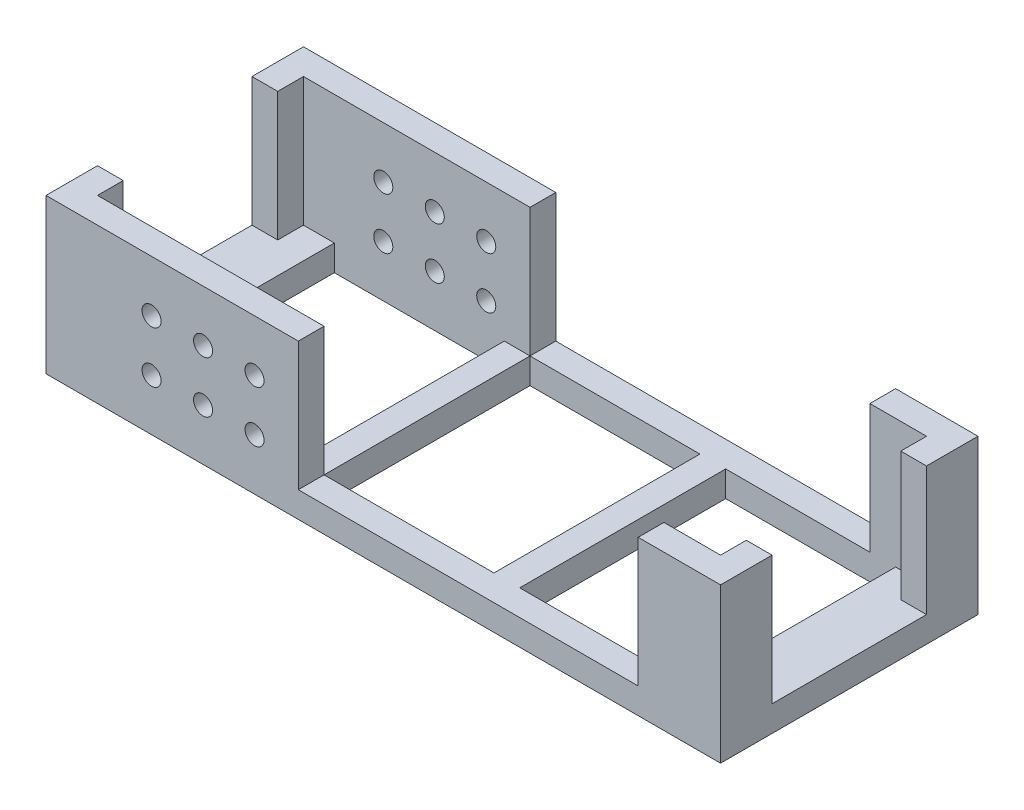
from build123d import *

# Parameters (mm, degrees)
SKETCH1_W                = 131
SKETCH1_H                = 50
BOSS_EXTRUDE6_DEPTH      = 5
SKETCH11_W               = 33
SKETCH11_H               = 40
CUT_EXTRUDE7_DEPTH       = 5
BOSS_EXTRUDE7_DEPTH      = 30
SKETCH13_W               = 30
SKETCH13_H               = 25
CUT_EXTRUDE8_DEPTH       = 66.5
CUT_EXTRUDE8_DEPTH_BACK  = 66.5
SKETCH15_R               = 1.85
CUT_EXTRUDE10_DEPTH      = 26
CUT_EXTRUDE10_DEPTH_BACK = 26


with BuildPart() as part:
    # Sketch1 → Boss-Extrude6 (new body)
    with BuildSketch(Plane(origin=(0, 0, 0), x_dir=(1, 0, 0), z_dir=(0, 1, 0))):
        Rectangle(SKETCH1_W, SKETCH1_H)
    extrude(amount=BOSS_EXTRUDE6_DEPTH)

    # Sketch11 → Cut-Extrude7 (cut)
    with BuildSketch(Plane(origin=(0, 0, 0), x_dir=(1, 0, 0), z_dir=(0, 1, 0))):
        with Locations((38, 0)):
            Rectangle(SKETCH11_W, SKETCH11_H)
        Rectangle(SKETCH11_W, SKETCH11_H)
        with Locations((-38, 0)):
            Rectangle(SKETCH11_W, SKETCH11_H)
    extrude(amount=CUT_EXTRUDE7_DEPTH, mode=Mode.SUBTRACT)

    # Sketch12 → Boss-Extrude7 (add)
    with BuildSketch(Plane(origin=(0, 0, 0), x_dir=(1, 0, 0), z_dir=(0, 1, 0))):
        Polygon((-65.5, -20), (-65.5, -25), (-59, -25), (-16.5, -25), (-16.5, -20), (-60.5, -20), (-60.5, 20), (-16.5, 20), (-16.5, 25), (-59, 25), (-65.5, 25), (-65.5, 20), align=None)
        Polygon((49.5, 25), (49.5, 20), (60.5, 20), (60.5, -20), (49.5, -20), (49.5, -25), (65.5, -25), (65.5, 25), align=None)
    extrude(amount=BOSS_EXTRUDE7_DEPTH)

    # Sketch13 → Cut-Extrude8 (cut, two sides)
    with BuildSketch(Plane(origin=(0, 0, 0), x_dir=(0, 0, -1), z_dir=(1, 0, 0))) as cut_extrude8_sk:
        with Locations((0, 17.5)):
            Rectangle(SKETCH13_W, SKETCH13_H)
    extrude(amount=CUT_EXTRUDE8_DEPTH, mode=Mode.SUBTRACT)
    extrude(cut_extrude8_sk.sketch, amount=-CUT_EXTRUDE8_DEPTH_BACK, mode=Mode.SUBTRACT)

    # Sketch15 → Cut-Extrude10 (cut, two sides)
    with BuildSketch(Plane.XY) as cut_extrude10_sk:
        with Locations((-35, 10)):
            Circle(SKETCH15_R)
        with Locations((-35, 20)):
            Circle(SKETCH15_R)
        with Locations((-25, 20)):
            Circle(SKETCH15_R)
        with Locations((-25, 10)):
            Circle(SKETCH15_R)
        with Locations((-45, 20)):
            Circle(SKETCH15_R)
        with Locations((-45, 10)):
            Circle(SKETCH15_R)
    extrude(amount=CUT_EXTRUDE10_DEPTH, mode=Mode.SUBTRACT)
    extrude(cut_extrude10_sk.sketch, amount=-CUT_EXTRUDE10_DEPTH_BACK, mode=Mode.SUBTRACT)


solid = part.part
